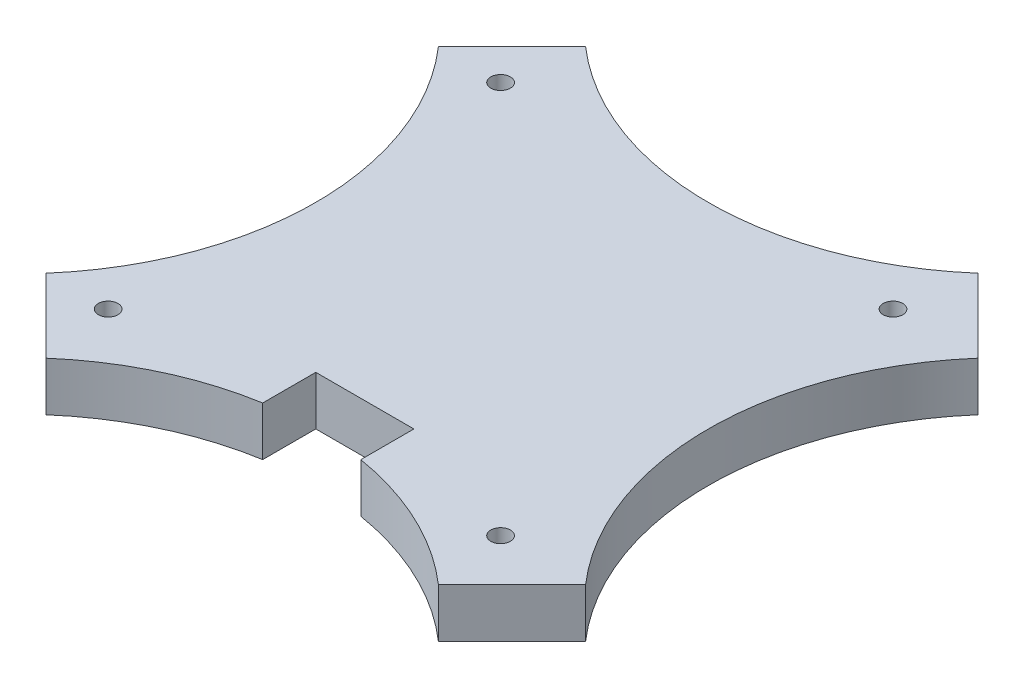
from build123d import *

# Parameters (mm, degrees)
SKETCH1_R           = 1
BOSS_EXTRUDE1_DEPTH = 5


with BuildPart() as part:
    # Sketch1 → Boss-Extrude1 (new body)
    with BuildSketch(Plane(origin=(0, 0, 0), x_dir=(1, 0, 0), z_dir=(0, 1, 0))):
        with BuildLine():
            ThreePointArc((-1438.835902455, 989.336226708), (-1446.828348365, 986.835514311), (-1453.835902334, 982.25))
            Line((-1453.835902334, 982.25), (-1461.335900746, 989.750001588))
            ThreePointArc((-1461.335900746, 989.750001588), (-1453.835896511, 1009.75), (-1461.335892276, 1029.750001588))
            Line((-1461.335892276, 1029.750001588), (-1453.835890688, 1037.25))
            ThreePointArc((-1453.835890688, 1037.25), (-1433.835890688, 1029.75), (-1413.835890688, 1037.25))
            Line((-1413.835890688, 1037.25), (-1406.335890688, 1029.749996824))
            ThreePointArc((-1406.335890688, 1029.749996824), (-1413.835886887, 1009.750002768), (-1406.335890688, 989.750008712))
            Line((-1406.335890688, 989.750008712), (-1413.835902577, 982.25))
            ThreePointArc((-1413.835902577, 982.25), (-1420.843456545, 986.835514311), (-1428.835902455, 989.336226708))
            Line((-1428.835902455, 989.336226708), (-1428.835902455, 989.75))
            Line((-1428.835902455, 989.75), (-1428.835902455, 994.75))
            Line((-1428.835902455, 994.75), (-1433.835902455, 994.75))
            Line((-1433.835902455, 994.75), (-1438.835902455, 994.75))
            Line((-1438.835902455, 994.75), (-1438.835902455, 989.75))
            Line((-1438.835902455, 989.75), (-1438.835902455, 989.336226708))
        make_face()
        with Locations((-1415, 989.75)):
            Circle(SKETCH1_R, mode=Mode.SUBTRACT)
        with Locations((-1455.000010057, 989.75)):
            Circle(SKETCH1_R, mode=Mode.SUBTRACT)
        with Locations((-1415, 1029.75)):
            Circle(SKETCH1_R, mode=Mode.SUBTRACT)
        with Locations((-1455.000001588, 1029.75)):
            Circle(SKETCH1_R, mode=Mode.SUBTRACT)
    extrude(amount=BOSS_EXTRUDE1_DEPTH)


solid = part.part
